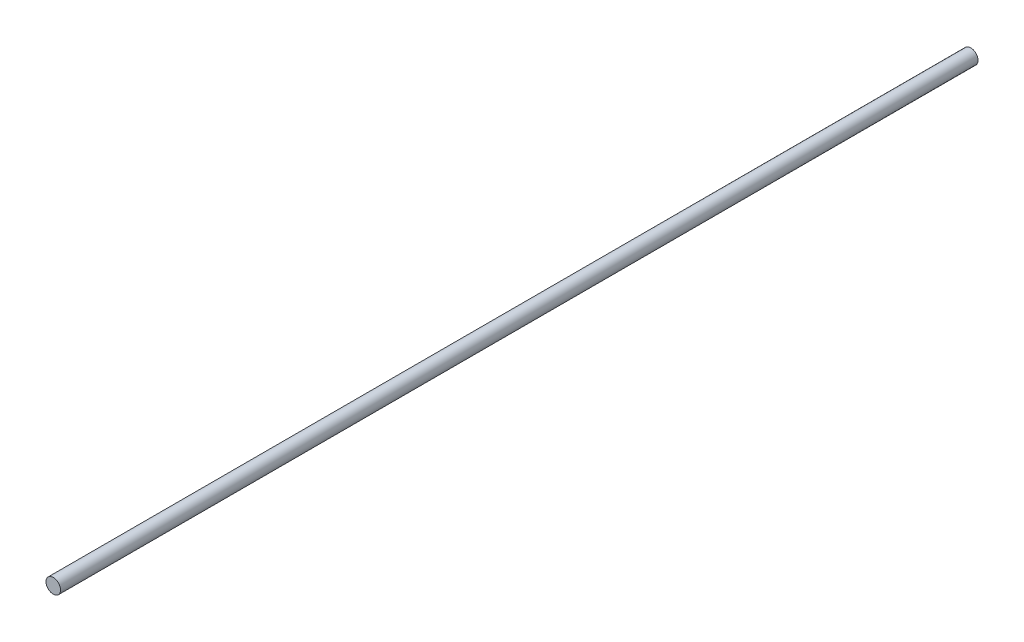
from build123d import *

# Parameters (mm, degrees)
SKETCH1_R           = 3.175
BOSS_EXTRUDE1_DEPTH = 400


with BuildPart() as part:
    # Sketch1 → Boss-Extrude1 (new body)
    with BuildSketch(Plane.XY):
        Circle(SKETCH1_R)
    extrude(amount=BOSS_EXTRUDE1_DEPTH)


solid = part.part
